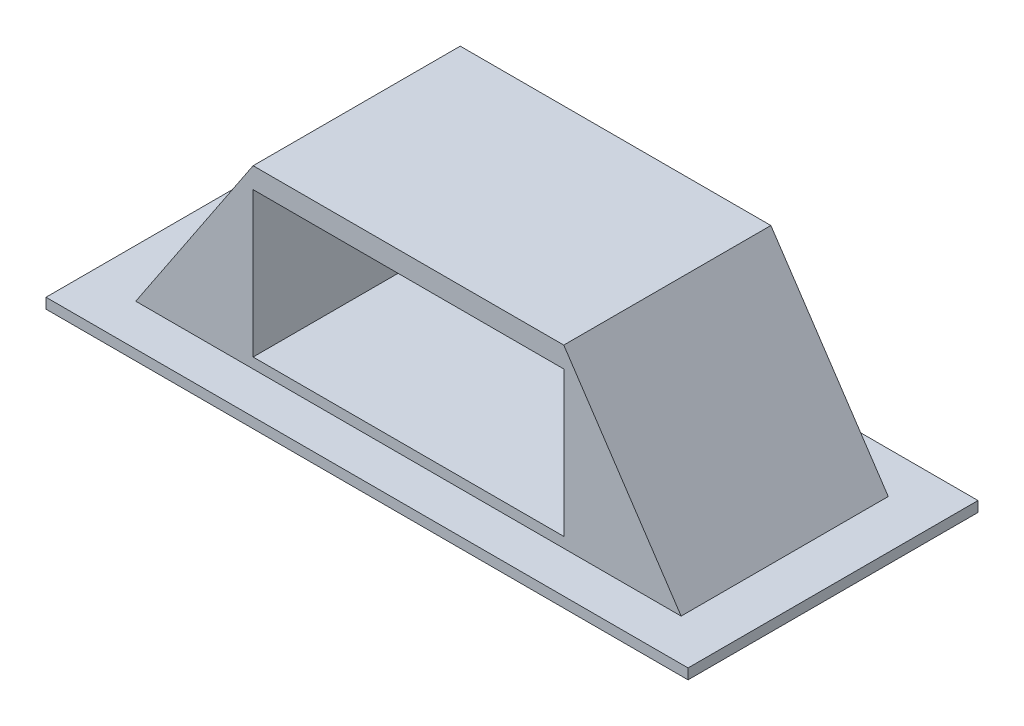
from build123d import *

# Parameters (mm, degrees)
SKETCH_2_W          = 150
SKETCH_2_H          = 100
EXTRUDE_1_DEPTH     = 90
SKETCH_3_W          = 150
SKETCH_3_H          = 70
CUT_EXTRUDE_1_DEPTH = 80
EXTRUDE_2_DEPTH     = 100
EXTRUDE_3_DEPTH     = 100
SKETCH_7_W          = 310
SKETCH_7_H          = 140
EXTRUDE_4_DEPTH     = 5


with BuildPart() as part:
    # 草图2 → 凸台-拉伸1 (new body)
    with BuildSketch(Plane(origin=(0, 0, 0), x_dir=(1, 0, 0), z_dir=(0, 1, 0))):
        Rectangle(SKETCH_2_W, SKETCH_2_H)
    extrude(amount=EXTRUDE_1_DEPTH)

    # 草图3 → 切除-拉伸1 (cut)
    with BuildSketch(Plane.XY.offset(50)):
        with Locations((0, 45)):
            Rectangle(SKETCH_3_W, SKETCH_3_H)
    extrude(amount=-CUT_EXTRUDE_1_DEPTH, mode=Mode.SUBTRACT)

    # 草图5 → 凸台-拉伸2 (add)
    with BuildSketch(Plane(origin=(0, 0, -50), x_dir=(-1, 0, 0), z_dir=(0, 0, -1))):
        Polygon((-75, 90), (-135, 0), (-75, 0), align=None)
    extrude(amount=-EXTRUDE_2_DEPTH)

    # 草图6 → 凸台-拉伸3 (add)
    with BuildSketch(Plane(origin=(0, 0, -50), x_dir=(-1, 0, 0), z_dir=(0, 0, -1))):
        Polygon((75, 90), (135, 0), (75, 0), align=None)
    extrude(amount=-EXTRUDE_3_DEPTH)

    # 草图7 → 凸台-拉伸4 (add)
    with BuildSketch(Plane.XZ):
        Rectangle(SKETCH_7_W, SKETCH_7_H)
    extrude(amount=-EXTRUDE_4_DEPTH)


solid = part.part
